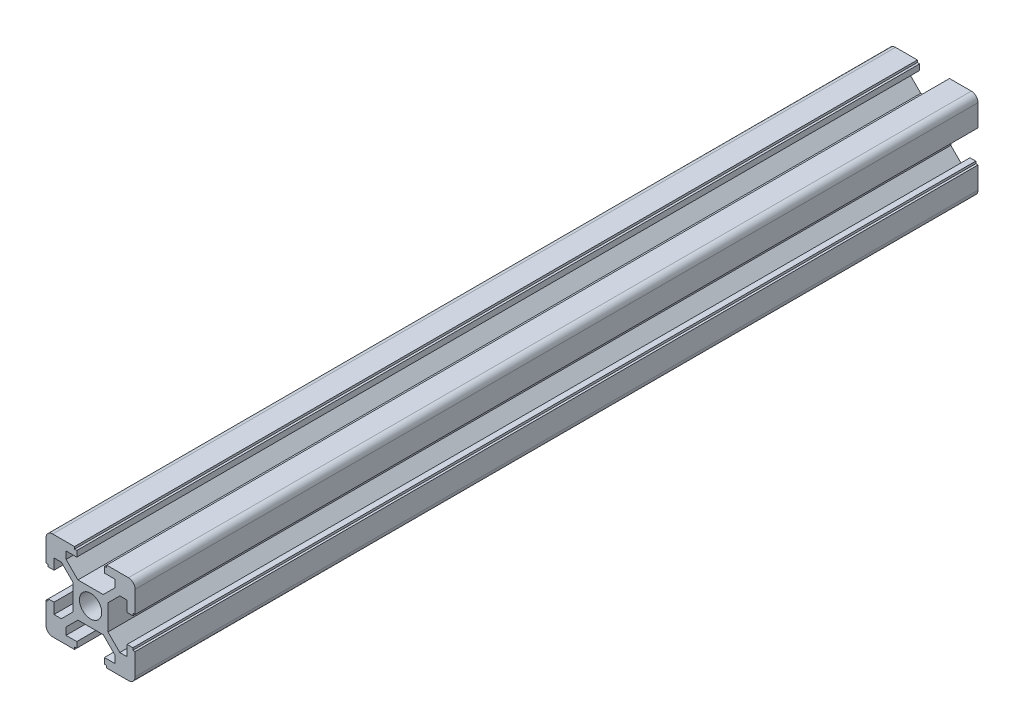
from build123d import *

# Parameters (mm, degrees)
SKETCH1_R           = 2.5
BOSS_EXTRUDE1_DEPTH = 189.096108091
SCALE_2_SCALE       = 3
SCALE_3_SCALE       = 6
SCALE_5_SCALE       = 2
SCALE_6_SCALE       = 0.25
SCALE_7_SCALE       = 0.125
SCALE_8_SCALE       = 0.25
SCALE_9_SCALE       = 4
SCALE_10_SCALE      = 4


with BuildPart() as part:
    # Sketch1 → Boss-Extrude1 (new body)
    with BuildSketch(Plane.XY):
        with BuildLine():
            Line((2.839339828, 3.9), (5.5, 6.560660172))
            Line((5.5, 6.560660172), (5.5, 8.2))
            Line((5.5, 8.2), (3.1, 8.2))
            Line((3.1, 8.2), (3.1, 9.5))
            Line((3.1, 9.5), (3.6, 9.5))
            Line((3.6, 9.5), (3.6, 10))
            Line((3.6, 10), (8.5, 10))
            ThreePointArc((8.5, 10), (9.560660172, 9.560660172), (10, 8.5))
            Line((10, 8.5), (10, 3.6))
            Line((10, 3.6), (9.5, 3.6))
            Line((9.5, 3.6), (9.5, 3.1))
            Line((9.5, 3.1), (8.2, 3.1))
            Line((8.2, 3.1), (8.2, 5.5))
            Line((8.2, 5.5), (6.560660172, 5.5))
            Line((6.560660172, 5.5), (3.9, 2.839339828))
            Line((3.9, 2.839339828), (3.9, -2.839339828))
            Line((3.9, -2.839339828), (6.560660172, -5.5))
            Line((6.560660172, -5.5), (8.2, -5.5))
            Line((8.2, -5.5), (8.2, -3.1))
            Line((8.2, -3.1), (9.5, -3.1))
            Line((9.5, -3.1), (9.5, -3.6))
            Line((9.5, -3.6), (10, -3.6))
            Line((10, -3.6), (10, -8.5))
            ThreePointArc((10, -8.5), (9.560660172, -9.560660172), (8.5, -10))
            Line((8.5, -10), (3.6, -10))
            Line((3.6, -10), (3.6, -9.5))
            Line((3.6, -9.5), (3.1, -9.5))
            Line((3.1, -9.5), (3.1, -8.2))
            Line((3.1, -8.2), (5.5, -8.2))
            Line((5.5, -8.2), (5.5, -6.560660172))
            Line((5.5, -6.560660172), (2.839339828, -3.9))
            Line((2.839339828, -3.9), (-2.839339828, -3.9))
            Line((-2.839339828, -3.9), (-5.5, -6.560660172))
            Line((-5.5, -6.560660172), (-5.5, -8.2))
            Line((-5.5, -8.2), (-3.1, -8.2))
            Line((-3.1, -8.2), (-3.1, -9.5))
            Line((-3.1, -9.5), (-3.6, -9.5))
            Line((-3.6, -9.5), (-3.6, -10))
            Line((-3.6, -10), (-8.5, -10))
            ThreePointArc((-8.5, -10), (-9.560660172, -9.560660172), (-10, -8.5))
            Line((-10, -8.5), (-10, -3.6))
            Line((-10, -3.6), (-9.5, -3.6))
            Line((-9.5, -3.6), (-9.5, -3.1))
            Line((-9.5, -3.1), (-8.2, -3.1))
            Line((-8.2, -3.1), (-8.2, -5.5))
            Line((-8.2, -5.5), (-6.560660172, -5.5))
            Line((-6.560660172, -5.5), (-3.9, -2.839339828))
            Line((-3.9, -2.839339828), (-3.9, 2.839339828))
            Line((-3.9, 2.839339828), (-6.560660172, 5.5))
            Line((-6.560660172, 5.5), (-8.2, 5.5))
            Line((-8.2, 5.5), (-8.2, 3.1))
            Line((-8.2, 3.1), (-9.5, 3.1))
            Line((-9.5, 3.1), (-9.5, 3.6))
            Line((-9.5, 3.6), (-10, 3.6))
            Line((-10, 3.6), (-10, 8.5))
            ThreePointArc((-10, 8.5), (-9.560660172, 9.560660172), (-8.5, 10))
            Line((-8.5, 10), (-3.6, 10))
            Line((-3.6, 10), (-3.6, 9.5))
            Line((-3.6, 9.5), (-3.1, 9.5))
            Line((-3.1, 9.5), (-3.1, 8.2))
            Line((-3.1, 8.2), (-5.5, 8.2))
            Line((-5.5, 8.2), (-5.5, 6.560660172))
            Line((-5.5, 6.560660172), (-2.839339828, 3.9))
            Line((-2.839339828, 3.9), (2.839339828, 3.9))
        make_face()
        with Locations((0, 0.235847297)):
            Circle(SKETCH1_R, mode=Mode.SUBTRACT)
    extrude(amount=BOSS_EXTRUDE1_DEPTH)


with BuildPart() as part_1:
    # 缩放比例2: scaled about (0, -0.027095247, 94.548054046)
    add(part.part.scale(SCALE_2_SCALE).moved(Location((0, 0.054190494, -189.096108092))))


with BuildPart() as part_2:
    # 缩放比例3: scaled about (0, -0.027095247, 94.548054045)
    add(part_1.part.scale(SCALE_3_SCALE).moved(Location((0, 0.135476235, -472.740270225))))


with BuildPart() as part_3:
    # 缩放比例5: scaled about (0, -0.027095249, 94.548054043)
    add(part_2.part.scale(SCALE_5_SCALE).moved(Location((0, 0.027095249, -94.548054043))))


with BuildPart() as part_4:
    # 缩放比例6: scaled about (0, -0.027095249, 94.548054044)
    add(part_3.part.scale(SCALE_6_SCALE).moved(Location((0, -0.020321437, 70.911040533))))


with BuildPart() as part_5:
    # 缩放比例7: scaled about (0, -0.027095249, 94.548054044)
    add(part_4.part.scale(SCALE_7_SCALE).moved(Location((0, -0.023708343, 82.729547289))))


with BuildPart() as part_6:
    # 缩放比例8: scaled about (0, -0.027095249, 94.548054044)
    add(part_5.part.scale(SCALE_8_SCALE).moved(Location((0, -0.020321437, 70.911040533))))


with BuildPart() as part_7:
    # 缩放比例9: scaled about (0, -0.027095249, 94.548054044)
    add(part_6.part.scale(SCALE_9_SCALE).moved(Location((0, 0.081285747, -283.644162132))))


with BuildPart() as part_8:
    # 缩放比例10: scaled about (0, -0.027095249, 94.548054044)
    add(part_7.part.scale(SCALE_10_SCALE).moved(Location((0, 0.081285747, -283.644162132))))


solid = part_8.part
